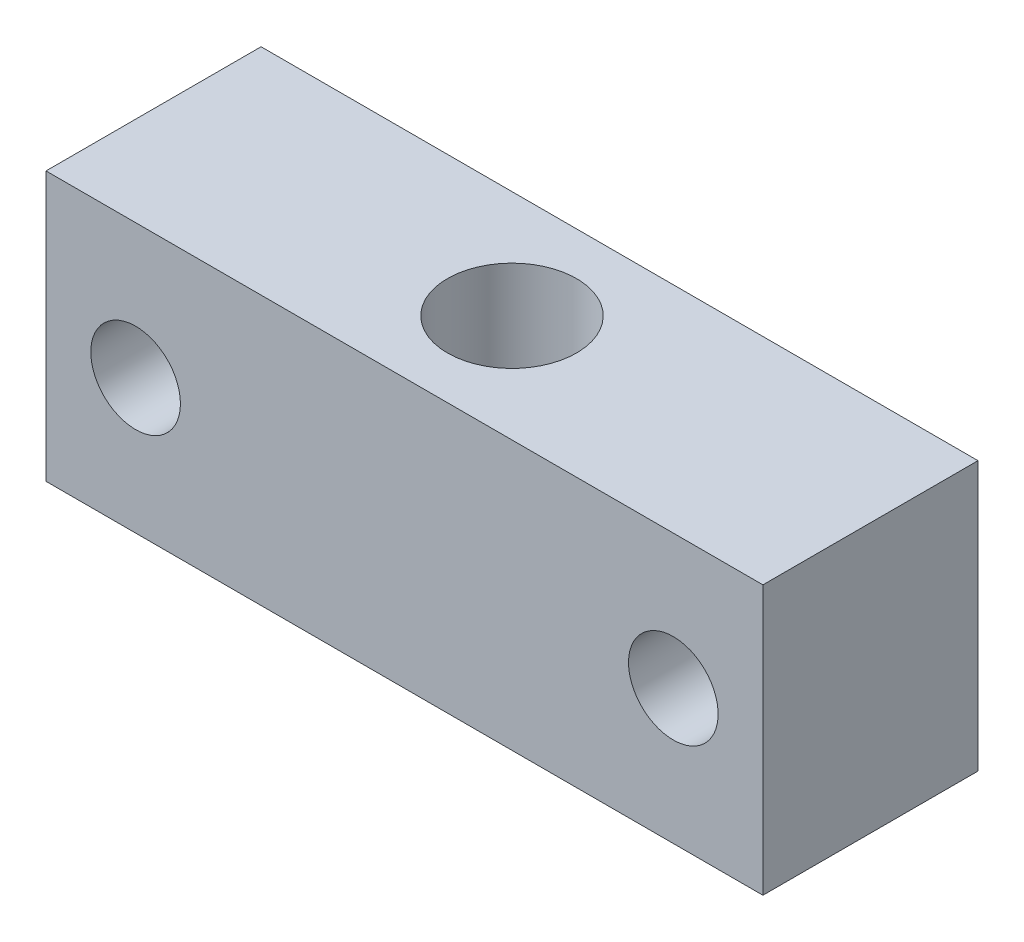
from build123d import *

# Parameters (mm, degrees)
SKETCH_1_W          = 40
SKETCH_1_H          = 12
SKETCH_1_R          = 3.6
EXTRUDE_1_DEPTH     = 15
SKETCH_2_R          = 2.5
CUT_EXTRUDE_1_DEPTH = 13


with BuildPart() as part:
    # Эскиз1 → Бобышка-Вытянуть1 (new body)
    with BuildSketch(Plane(origin=(0, 0, 0), x_dir=(1, 0, 0), z_dir=(0, 1, 0))):
        Rectangle(SKETCH_1_W, SKETCH_1_H)
        Circle(SKETCH_1_R, mode=Mode.SUBTRACT)
    extrude(amount=EXTRUDE_1_DEPTH)

    # Эскиз2 → Вырез-Вытянуть1 (cut, through all)
    with BuildSketch(Plane.XY.offset(6)):
        with Locations((-15, 7.5)):
            Circle(SKETCH_2_R)
        with Locations((15, 7.5)):
            Circle(SKETCH_2_R)
    extrude(amount=-CUT_EXTRUDE_1_DEPTH, mode=Mode.SUBTRACT)


solid = part.part
